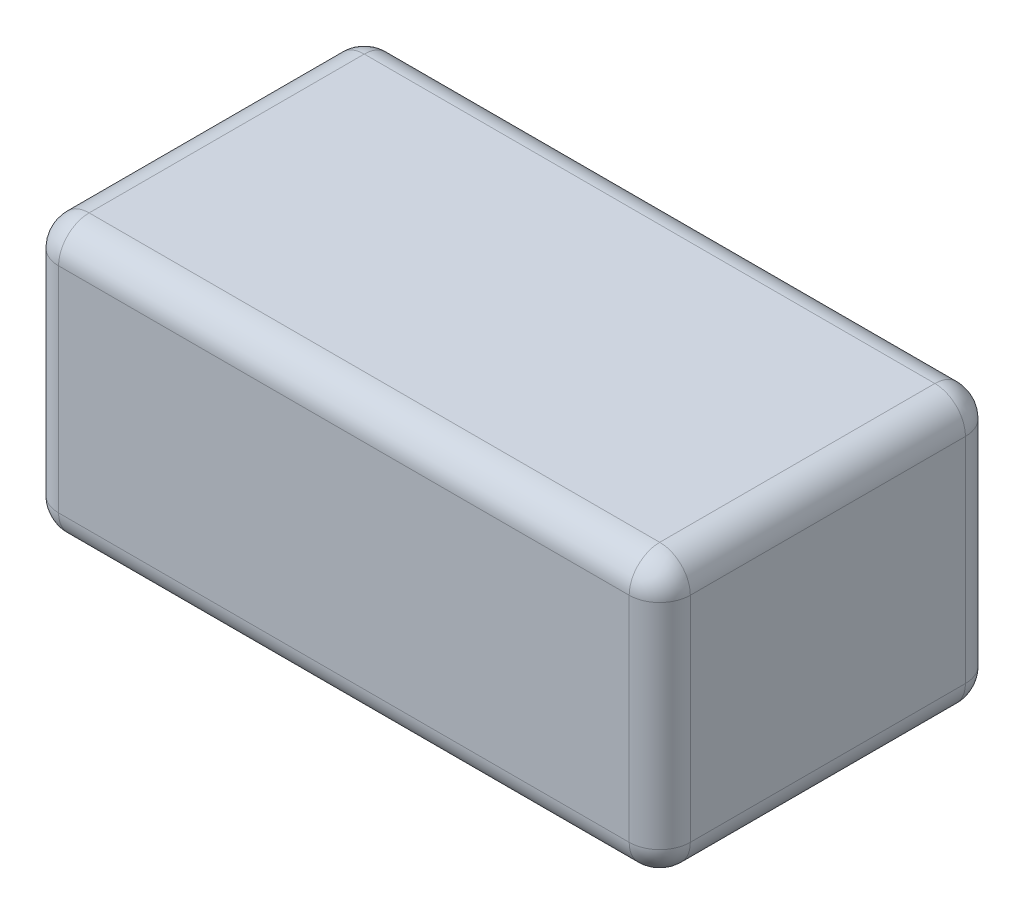
from build123d import *

# Parameters (mm, degrees)
SKETCH1_W           = 33
SKETCH1_H           = 27
BOSS_EXTRUDE1_DEPTH = 62
FILLET1_R           = 3


with BuildPart() as part:
    # Sketch1 → Boss-Extrude1 (new body)
    with BuildSketch(Plane(origin=(0, 0, 0), x_dir=(0, 0, -1), z_dir=(1, 0, 0))):
        with Locations((-16.5, 13.5)):
            Rectangle(SKETCH1_W, SKETCH1_H)
    extrude(amount=-BOSS_EXTRUDE1_DEPTH)

    # Fillet1
    fillet1_edges = [part.edges().sort_by_distance(p)[0] for p in [
        (-62, 13.5, 33),
        (-62, 0, 16.5),
        (-62, 13.5, 0),
        (0, 0, 16.5),
        (0, 13.5, 33),
        (0, 27, 16.5),
        (0, 13.5, 0),
        (-31, 0, 0),
        (-31, 0, 33),
        (-31, 27, 33),
        (-31, 27, 0),
        (-62, 27, 16.5),
    ]]
    fillet(fillet1_edges, radius=FILLET1_R)


solid = part.part
